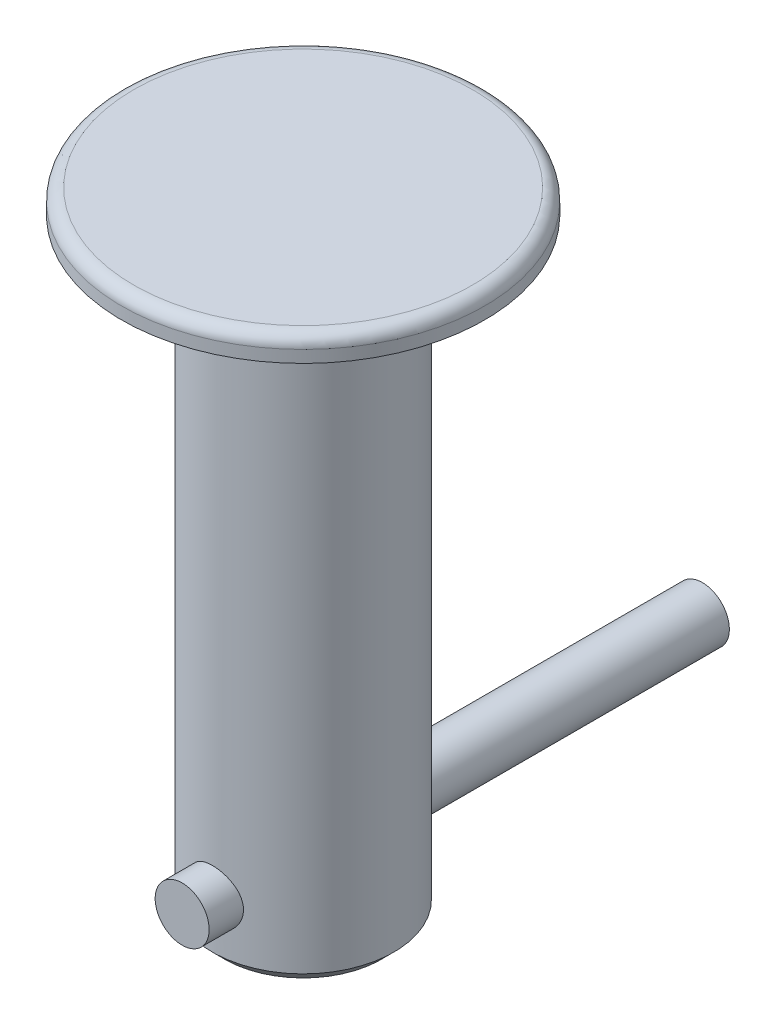
from build123d import *

# Parameters (mm, degrees)
IZIM1_W                          = 7.5
IZIM1_H                          = 50
IZIM1_W_2                        = 15
IZIM1_H_2                        = 2
PAH1_SIZE                        = 1
RADYUS1_R                        = 1
IZIM2_R                          = 2.230391283
Y_KSEKLIK_EKSTR_ZYON1_DEPTH      = 10
Y_KSEKLIK_EKSTR_ZYON1_DEPTH_BACK = 33


with BuildPart() as part:
    # Çizim1 → Döndür1 (revolve)
    with BuildSketch(Plane.XY):
        with Locations((-3.75, -25)):
            Rectangle(IZIM1_W, IZIM1_H)
        with Locations((-7.5, 1)):
            Rectangle(IZIM1_W_2, IZIM1_H_2)
    revolve(axis=Axis((0, 0, 0), (0, -1, 0)))

    # Pah1
    pah1_edges = [part.edges().sort_by_distance(p)[0] for p in [
        (7.5, -50, 0),
    ]]
    chamfer(pah1_edges, length=PAH1_SIZE)

    # Radyus1
    radyus1_edges = [part.edges().sort_by_distance(p)[0] for p in [
        (15, 2, 0),
    ]]
    fillet(radyus1_edges, radius=RADYUS1_R)

    # Çizim2 → Yükseklik-Ekstrüzyon1 (add, two sides)
    with BuildSketch(Plane.XY) as y_kseklik_ekstr_zyon1_sk:
        with Locations((0, -45.019745936)):
            Circle(IZIM2_R)
    extrude(amount=Y_KSEKLIK_EKSTR_ZYON1_DEPTH)
    extrude(y_kseklik_ekstr_zyon1_sk.sketch, amount=-Y_KSEKLIK_EKSTR_ZYON1_DEPTH_BACK)


solid = part.part
